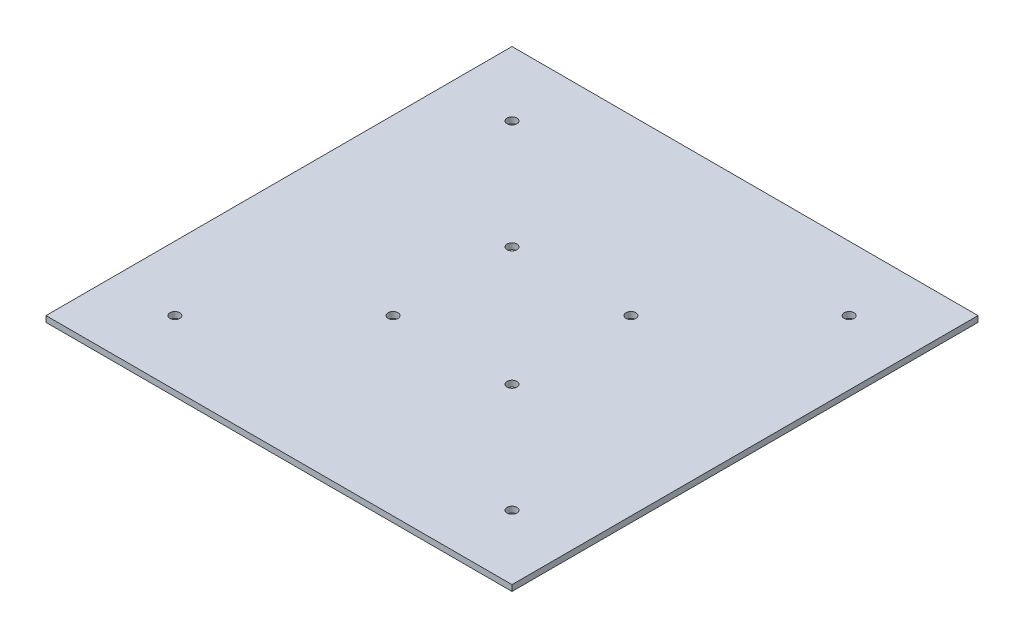
from build123d import *

# Parameters (mm, degrees)
SKETCH1_W           = 235
SKETCH1_H           = 235
BOSS_EXTRUDE1_DEPTH = 3
CUT_EXTRUDE1_REACH  = 5
SKETCH2_R           = 2.5


with BuildPart() as part:
    # Sketch1 → Boss-Extrude1 (new body)
    with BuildSketch(Plane(origin=(0, 0, 0), x_dir=(1, 0, 0), z_dir=(0, 1, 0))):
        with Locations((117.5, 117.5)):
            Rectangle(SKETCH1_W, SKETCH1_H)
    extrude(amount=BOSS_EXTRUDE1_DEPTH)

    # Sketch2 → Cut-Extrude1 (cut, up to next)
    with BuildSketch(Plane(origin=(0, 3, 0), x_dir=(1, 0, 0), z_dir=(0, 1, 0)), mode=Mode.PRIVATE) as cut_extrude1_sk1:
        with Locations((32.5, 202.5)):
            Circle(SKETCH2_R)
    cut_extrude1_tool1 = extrude(cut_extrude1_sk1.sketch, amount=-CUT_EXTRUDE1_REACH, mode=Mode.PRIVATE) & part.part
    add(cut_extrude1_tool1.solids().sort_by_distance((32.5, 3, -202.5))[0], mode=Mode.SUBTRACT)
    # Sketch2 → Cut-Extrude1 (cut, up to next)
    with BuildSketch(Plane(origin=(0, 3, 0), x_dir=(1, 0, 0), z_dir=(0, 1, 0)), mode=Mode.PRIVATE) as cut_extrude1_sk2:
        with Locations((202.5, 202.5)):
            Circle(SKETCH2_R)
    cut_extrude1_tool2 = extrude(cut_extrude1_sk2.sketch, amount=-CUT_EXTRUDE1_REACH, mode=Mode.PRIVATE) & part.part
    add(cut_extrude1_tool2.solids().sort_by_distance((202.5, 3, -202.5))[0], mode=Mode.SUBTRACT)
    # Sketch2 → Cut-Extrude1 (cut, up to next)
    with BuildSketch(Plane(origin=(0, 3, 0), x_dir=(1, 0, 0), z_dir=(0, 1, 0)), mode=Mode.PRIVATE) as cut_extrude1_sk3:
        with Locations((202.5, 32.5)):
            Circle(SKETCH2_R)
    cut_extrude1_tool3 = extrude(cut_extrude1_sk3.sketch, amount=-CUT_EXTRUDE1_REACH, mode=Mode.PRIVATE) & part.part
    add(cut_extrude1_tool3.solids().sort_by_distance((202.5, 3, -32.5))[0], mode=Mode.SUBTRACT)
    # Sketch2 → Cut-Extrude1 (cut, up to next)
    with BuildSketch(Plane(origin=(0, 3, 0), x_dir=(1, 0, 0), z_dir=(0, 1, 0)), mode=Mode.PRIVATE) as cut_extrude1_sk4:
        with Locations((32.5, 32.5)):
            Circle(SKETCH2_R)
    cut_extrude1_tool4 = extrude(cut_extrude1_sk4.sketch, amount=-CUT_EXTRUDE1_REACH, mode=Mode.PRIVATE) & part.part
    add(cut_extrude1_tool4.solids().sort_by_distance((32.5, 3, -32.5))[0], mode=Mode.SUBTRACT)
    # Sketch2 → Cut-Extrude1 (cut, up to next)
    with BuildSketch(Plane(origin=(0, 3, 0), x_dir=(1, 0, 0), z_dir=(0, 1, 0)), mode=Mode.PRIVATE) as cut_extrude1_sk5:
        with Locations((87.5, 147.5)):
            Circle(SKETCH2_R)
    cut_extrude1_tool5 = extrude(cut_extrude1_sk5.sketch, amount=-CUT_EXTRUDE1_REACH, mode=Mode.PRIVATE) & part.part
    add(cut_extrude1_tool5.solids().sort_by_distance((87.5, 3, -147.5))[0], mode=Mode.SUBTRACT)
    # Sketch2 → Cut-Extrude1 (cut, up to next)
    with BuildSketch(Plane(origin=(0, 3, 0), x_dir=(1, 0, 0), z_dir=(0, 1, 0)), mode=Mode.PRIVATE) as cut_extrude1_sk6:
        with Locations((147.5, 147.5)):
            Circle(SKETCH2_R)
    cut_extrude1_tool6 = extrude(cut_extrude1_sk6.sketch, amount=-CUT_EXTRUDE1_REACH, mode=Mode.PRIVATE) & part.part
    add(cut_extrude1_tool6.solids().sort_by_distance((147.5, 3, -147.5))[0], mode=Mode.SUBTRACT)
    # Sketch2 → Cut-Extrude1 (cut, up to next)
    with BuildSketch(Plane(origin=(0, 3, 0), x_dir=(1, 0, 0), z_dir=(0, 1, 0)), mode=Mode.PRIVATE) as cut_extrude1_sk7:
        with Locations((147.5, 87.5)):
            Circle(SKETCH2_R)
    cut_extrude1_tool7 = extrude(cut_extrude1_sk7.sketch, amount=-CUT_EXTRUDE1_REACH, mode=Mode.PRIVATE) & part.part
    add(cut_extrude1_tool7.solids().sort_by_distance((147.5, 3, -87.5))[0], mode=Mode.SUBTRACT)
    # Sketch2 → Cut-Extrude1 (cut, up to next)
    with BuildSketch(Plane(origin=(0, 3, 0), x_dir=(1, 0, 0), z_dir=(0, 1, 0)), mode=Mode.PRIVATE) as cut_extrude1_sk8:
        with Locations((87.5, 87.5)):
            Circle(SKETCH2_R)
    cut_extrude1_tool8 = extrude(cut_extrude1_sk8.sketch, amount=-CUT_EXTRUDE1_REACH, mode=Mode.PRIVATE) & part.part
    add(cut_extrude1_tool8.solids().sort_by_distance((87.5, 3, -87.5))[0], mode=Mode.SUBTRACT)


solid = part.part
